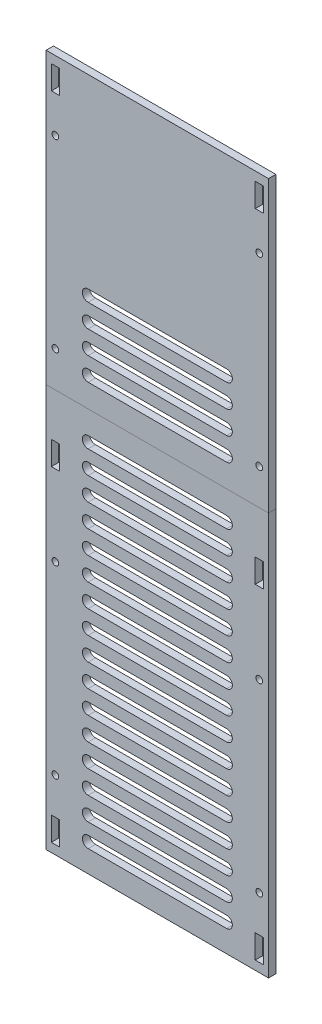
from build123d import *

# Parameters (mm, degrees)
SKETCH1_W              = 96.34
SKETCH1_H              = 300
BOSS_EXTRUDE1_DEPTH    = 1.5875
SKETCH1_3_W            = 3.4925
SKETCH1_3_H            = 10.25
CUT_EXTRUDE1_DEPTH     = 158.552750075
M2_5_CLEARANCE_HOLE1_D = 2.9
LPATTERN1_COUNT        = 4
LPATTERN1_PITCH        = 80
MIRROR1_COPY_1_D       = 2.9
MIRROR1_COPY_2_D       = 2.9
MIRROR1_COPY_3_D       = 2.9
MIRROR1_COPY_4_D       = 2.9
CUT_EXTRUDE2_DEPTH     = 158.576741701
LPATTERN2_COUNT        = 16
LPATTERN2_PITCH        = 10
CUT_EXTRUDE4_DEPTH     = 10
LPATTERN3_COUNT        = 4
LPATTERN3_PITCH        = 10


with BuildPart() as part:
    # Sketch1 → Boss-Extrude1 (new, symmetric)
    with BuildSketch(Plane.XY):
        Rectangle(SKETCH1_W, SKETCH1_H)
    extrude(amount=BOSS_EXTRUDE1_DEPTH, both=True)

    # Sketch1_3 → Cut-Extrude1 (cut, symmetric)
    with BuildSketch(Plane.XY):
        with Locations((-44.17, 141)):
            Rectangle(SKETCH1_3_W, SKETCH1_3_H)
        with Locations((-44.17, 0)):
            Rectangle(SKETCH1_3_W, SKETCH1_3_H)
        with Locations((-44.17, -141)):
            Rectangle(SKETCH1_3_W, SKETCH1_3_H)
    cut_extrude1 = extrude(amount=CUT_EXTRUDE1_DEPTH, both=True, mode=Mode.SUBTRACT)

    # M2.5 Clearance Hole1 (through all)
    with Locations(Plane.XY.offset(1.5875)):
        with Locations((-44.17, 120)):
            m2_5_clearance_hole1 = Hole(M2_5_CLEARANCE_HOLE1_D / 2)

    # LPattern1: M2.5 Clearance Hole1 ×4
    with Locations(*[(0, -i * LPATTERN1_PITCH, 0) for i in range(1, LPATTERN1_COUNT)]):
        add(m2_5_clearance_hole1, mode=Mode.SUBTRACT)

    # Mirror1: Cut-Extrude1 across plane
    add(cut_extrude1.mirror(Plane(origin=(0, 0, 0), x_dir=(0, 0, 1), z_dir=(1, 0, 0))), mode=Mode.SUBTRACT)

    # Mirror1 copy 1 (through all)
    with Locations(Plane(origin=(0, -80, 1.5875), x_dir=(-1, 0, 0), z_dir=(0, 0, 1))):
        with Locations((-44.17, -120)):
            Hole(MIRROR1_COPY_1_D / 2)

    # Mirror1 copy 2 (through all)
    with Locations(Plane(origin=(0, -160, 1.5875), x_dir=(-1, 0, 0), z_dir=(0, 0, 1))):
        with Locations((-44.17, -120)):
            Hole(MIRROR1_COPY_2_D / 2)

    # Mirror1 copy 3 (through all)
    with Locations(Plane(origin=(0, -240, 1.5875), x_dir=(-1, 0, 0), z_dir=(0, 0, 1))):
        with Locations((-44.17, -120)):
            Hole(MIRROR1_COPY_3_D / 2)

    # Mirror1 copy 4 (through all)
    with Locations(Plane(origin=(0, 0, 1.5875), x_dir=(-1, 0, 0), z_dir=(0, 0, 1))):
        with Locations((-44.17, -120)):
            Hole(MIRROR1_COPY_4_D / 2)

    # Sketch5 → Cut-Extrude2 (cut, symmetric)
    with BuildSketch(Plane(origin=(0, 0, -1.5875), x_dir=(-1, 0, 0), z_dir=(0, 0, -1))):
        with BuildLine():
            Line((-30, 14.5), (30, 14.5))
            ThreePointArc((30, 14.5), (32.5, 12), (30, 9.5))
            Line((30, 9.5), (-30, 9.5))
            ThreePointArc((-30, 9.5), (-32.5, 12), (-30, 14.5))
        make_face()
    cut_extrude2 = extrude(amount=CUT_EXTRUDE2_DEPTH, both=True, mode=Mode.SUBTRACT)

    # LPattern2: Cut-Extrude2 ×16
    with Locations(*[(0, -i * LPATTERN2_PITCH, 0) for i in range(1, LPATTERN2_COUNT)]):
        add(cut_extrude2, mode=Mode.SUBTRACT)

    # Sketch5_4 → Cut-Extrude4 (cut)
    with BuildSketch(Plane(origin=(0, 0, -1.5875), x_dir=(-1, 0, 0), z_dir=(0, 0, -1))):
        with BuildLine():
            Line((-30, 39.5), (30, 39.5))
            ThreePointArc((30, 39.5), (32.5, 37), (30, 34.5))
            Line((30, 34.5), (-30, 34.5))
            ThreePointArc((-30, 34.5), (-32.5, 37), (-30, 39.5))
        make_face()
    cut_extrude4 = extrude(amount=-CUT_EXTRUDE4_DEPTH, mode=Mode.SUBTRACT)

    # LPattern3: Cut-Extrude4 ×4
    with Locations(*[(0, i * LPATTERN3_PITCH, 0) for i in range(1, LPATTERN3_COUNT)]):
        add(cut_extrude4, mode=Mode.SUBTRACT)


with BuildPart() as body_2:
    # Split2: the piece on the far side of the plane
    add(part.part)
    split(bisect_by=Plane.ZX.offset(24.5), keep=Keep.BOTTOM)


with BuildPart() as part_1:
    add(part.part)

    # Split2
    split(bisect_by=Plane.ZX.offset(24.5), keep=Keep.TOP)


solid = Compound([body_2.part, part_1.part])
